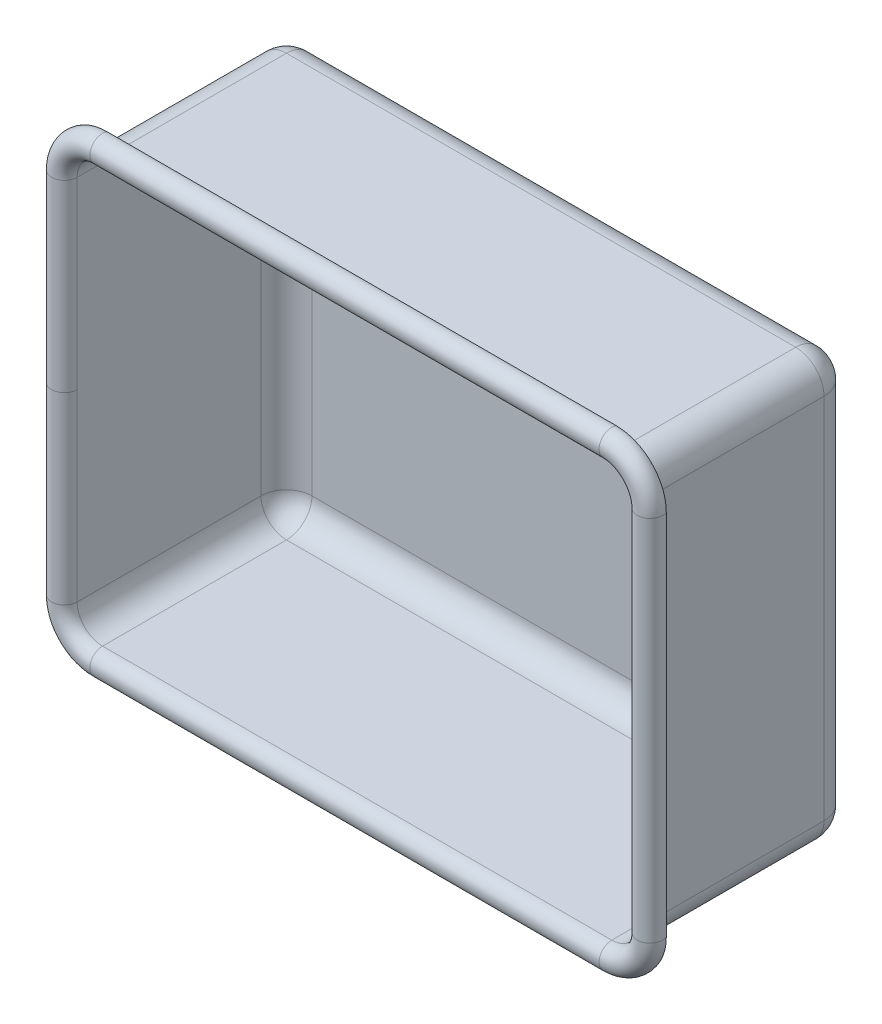
from build123d import *

# Parameters (mm, degrees)
SKETCH1_W           = 400
SKETCH1_H           = 300
BOSS_EXTRUDE1_DEPTH = 150
FILLET1_R           = 20
SHELL1_T            = -2


with BuildPart() as part:
    # Sketch1 → Boss-Extrude1 (new body)
    with BuildSketch(Plane.XY):
        Rectangle(SKETCH1_W, SKETCH1_H)
    extrude(amount=BOSS_EXTRUDE1_DEPTH)

    # Fillet1
    fillet1_edges = [part.edges().sort_by_distance(p)[0] for p in [
        (0, 150, 0),
        (200, 0, 0),
        (0, -150, 0),
        (-200, 0, 0),
        (-200, 150, 75),
        (200, 150, 75),
        (200, -150, 75),
        (-200, -150, 75),
    ]]
    fillet(fillet1_edges, radius=FILLET1_R)

    # Shell1
    shell1_openings = [part.faces().sort_by_distance(p)[0] for p in [
        (0, 0, 150),
    ]]
    offset(amount=SHELL1_T, openings=shell1_openings, kind=Kind.INTERSECTION)

    # Sweep2: sweep along a path in Sketch3
    with BuildLine(Plane.XY.offset(150)) as sweep2_path:
        Line((-180, -148), (180, -148))
        ThreePointArc((180, -148), (192.727922061, -142.727922061), (198, -130))
        Line((198, -130), (198, 130))
        ThreePointArc((198, 130), (192.727922061, 142.727922061), (180, 148))
        Line((180, 148), (-180, 148))
        ThreePointArc((-180, 148), (-192.727922061, 142.727922061), (-198, 130))
        Line((-198, 130), (-198, -130))
        ThreePointArc((-198, -130), (-192.727922061, -142.727922061), (-180, -148))
    # Sketch2 → Sweep2 (sweep)
    with BuildSketch(Plane(origin=(0, 0, 0), x_dir=(1, 0, 0), z_dir=(0, 1, 0))):
        with BuildLine():
            Line((-198, -150), (-200, -150))
            ThreePointArc((-200, -150), (-208.215537244, -156.893654271), (-213.577848346, -147.605858997))
            Line((-213.577848346, -147.605858997), (-215.457233587, -146.92181871))
            ThreePointArc((-215.457233587, -146.92181871), (-208.562833599, -158.863269777), (-198, -150))
        make_face()
    sweep(path=sweep2_path.line)


solid = part.part
